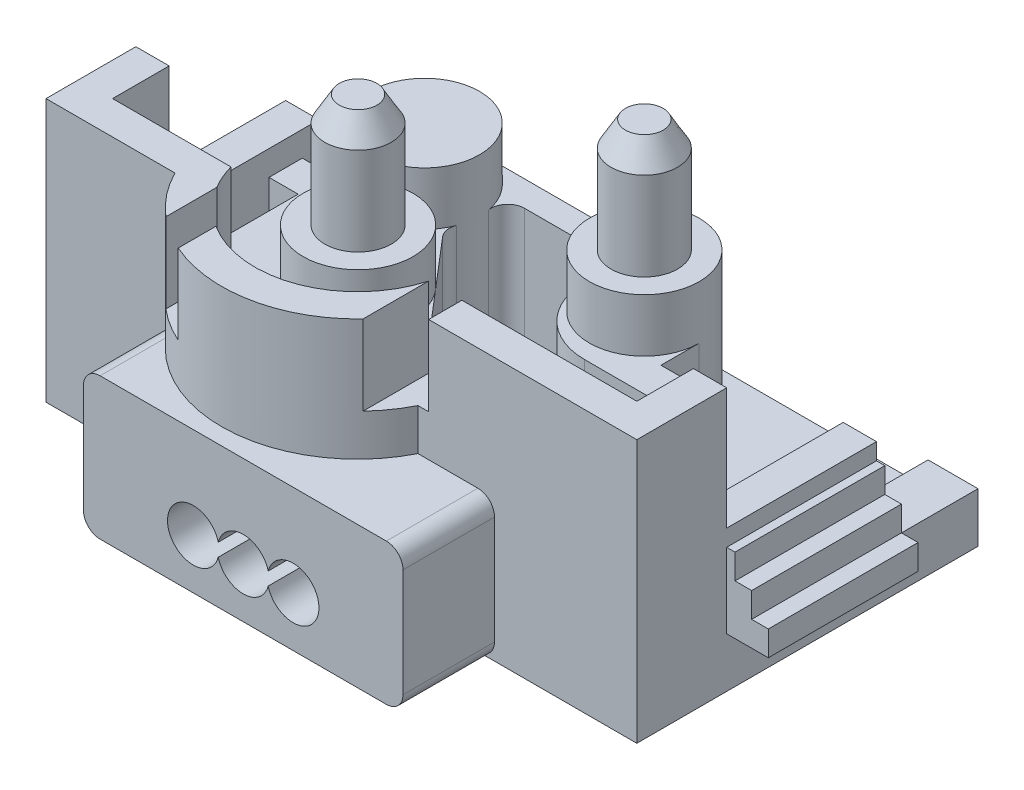
from build123d import *

# Parameters (mm, degrees)
SKETCH1_W             = 35.5
SKETCH1_H             = 20.5
BOSS_EXTRUDE1_DEPTH   = 1.5
BOSS_EXTRUDE2_DEPTH   = 1.5
BOSS_EXTRUDE4_DEPTH   = 9.5
SKETCH6_R             = 3.3
BOSS_EXTRUDE5_DEPTH   = 3.2
SKETCH7_R             = 2
BOSS_EXTRUDE6_DEPTH   = 6.8
BOSS_EXTRUDE6_2_DEPTH = 6.8
CHAMFER1_SIZE         = 1.5
CHAMFER1_SIZE2        = 0.866025404
CHAMFER2_SIZE         = 1.5
CHAMFER2_SIZE2        = 0.866025404
BOSS_EXTRUDE7_DEPTH   = 8
BOSS_EXTRUDE8_DEPTH   = 4.8
BOSS_EXTRUDE9_DEPTH   = 5.5
BOSS_EXTRUDE10_DEPTH  = 9
BOSS_EXTRUDE11_DEPTH  = 9
CUT_EXTRUDE4_DEPTH    = 5.5


with BuildPart() as part:
    # Sketch1 → Boss-Extrude1 (new body)
    with BuildSketch(Plane(origin=(0, 0, 0), x_dir=(1, 0, 0), z_dir=(0, 1, 0))):
        Rectangle(SKETCH1_W, SKETCH1_H)
    extrude(amount=BOSS_EXTRUDE1_DEPTH)

    # Sketch2 → Boss-Extrude2 (add)
    with BuildSketch(Plane(origin=(0, 1.5, 0), x_dir=(1, 0, 0), z_dir=(0, 1, 0))):
        Polygon((17.75, 10.25), (14.75, 10.25), (14.75, -8.25), (-14.75, -8.25), (-14.75, 10.25), (-17.75, 10.25), (-17.75, -10.25), (17.75, -10.25), align=None)
    extrude(amount=BOSS_EXTRUDE2_DEPTH)

    # Sketch4 → Boss-Extrude4 (add)
    with BuildSketch(Plane(origin=(0, 1.5, 0), x_dir=(1, 0, 0), z_dir=(0, 1, 0))):
        with BuildLine():
            ThreePointArc((9.8, 1.45), (8.833452378, 3.783452378), (6.5, 4.75))
            Line((6.5, 4.75), (-6.7, 4.75))
            ThreePointArc((-6.7, 4.75), (-9.033452378, 3.783452378), (-10, 1.45))
            Line((-10, 1.45), (-10, -0.85))
            Line((-10, -0.85), (-11.75, -0.85))
            Line((-11.75, -0.85), (-11.75, -2.85))
            Line((-11.75, -2.85), (-10, -2.85))
            Line((-10, -2.85), (-10, -8.25))
            Line((-10, -8.25), (3, -8.25))
            Line((3, -8.25), (-3.440516213, -0.729311618))
            ThreePointArc((-3.440516213, -0.729311618), (-3.666156861, -0.250346383), (-3.615628786, 0.276690914))
            ThreePointArc((-3.615628786, 0.276690914), (-3.413949819, 1.146892415), (-3.453044202, 2.03930302))
            ThreePointArc((-3.453044202, 2.03930302), (-3.236769385, 2.858747591), (-2.469118203, 3.217879692))
            Line((-2.469118203, 3.217879692), (2.269118203, 3.217879692))
            ThreePointArc((2.269118203, 3.217879692), (3.036769385, 2.858747591), (3.253044202, 2.03930302))
            ThreePointArc((3.253044202, 2.03930302), (3.213287803, 1.745842752), (3.2, 1.45))
            Line((3.2, 1.45), (3.2, 1.15))
            ThreePointArc((3.2, 1.15), (4.371572875, -1.678427125), (7.2, -2.85))
            Line((7.2, -2.85), (9.8, -2.85))
            Line((9.8, -2.85), (11.55, -2.85))
            Line((11.55, -2.85), (11.55, -0.85))
            Line((11.55, -0.85), (9.8, -0.85))
            Line((9.8, -0.85), (9.8, 1.45))
        make_face()
        with BuildLine():
            Line((3, -8.25), (-10, -8.25))
            Line((-10, -8.25), (-10, -10.25))
            ThreePointArc((-10, -10.25), (-2.7, -14.75), (4.6, -10.25))
            Line((4.6, -10.25), (4.6, -8.25))
            Line((4.6, -8.25), (3, -8.25))
        make_face()
    extrude(amount=BOSS_EXTRUDE4_DEPTH)

    # Sketch6 → Boss-Extrude5 (add)
    with BuildSketch(Plane(origin=(0, 11, 0), x_dir=(1, 0, 0), z_dir=(0, 1, 0))):
        with Locations((-6.7, 1.45)):
            Circle(SKETCH6_R)
        with Locations((6.5, 1.45)):
            Circle(SKETCH6_R)
        with Locations((-3.4, -5.85)):
            Circle(SKETCH6_R)
    extrude(amount=BOSS_EXTRUDE5_DEPTH)

    # Sketch8 → Boss-Extrude7 (add)
    with BuildSketch(Plane(origin=(0, 3, 0), x_dir=(1, 0, 0), z_dir=(0, 1, 0))):
        with BuildLine():
            Line((-17.75, -10.25), (-10, -10.25))
            ThreePointArc((-10, -10.25), (-2.7, -14.75), (4.6, -10.25))
            Line((4.6, -10.25), (17.75, -10.25))
            Line((17.75, -10.25), (17.75, -4.85))
            Line((17.75, -4.85), (15.75, -4.85))
            Line((15.75, -4.85), (15.75, -8.25))
            Line((15.75, -8.25), (14.75, -8.25))
            Line((14.75, -8.25), (4.6, -8.25))
            Line((4.6, -8.25), (3.240538696, -8.25))
            ThreePointArc((3.240538696, -8.25), (-2.7, -12.75), (-8.640538696, -8.25))
            Line((-8.640538696, -8.25), (-10, -8.25))
            Line((-10, -8.25), (-14.75, -8.25))
            Line((-14.75, -8.25), (-15.75, -8.25))
            Line((-15.75, -8.25), (-15.75, -4.85))
            Line((-15.75, -4.85), (-17.75, -4.85))
            Line((-17.75, -4.85), (-17.75, -10.25))
        make_face()
    extrude(amount=BOSS_EXTRUDE7_DEPTH)

    # Sketch9 → Boss-Extrude8 (add)
    with BuildSketch(Plane(origin=(0, 11, 0), x_dir=(1, 0, 0), z_dir=(0, 1, 0))):
        Polygon((17.75, -10.25), (17.75, -4.85), (15.75, -4.85), (15.75, -8.25), (5.240538696, -8.25), (5.240538696, -10.25), align=None)
        with BuildLine():
            Line((-17.75, -4.85), (-17.75, -10.25))
            Line((-17.75, -10.25), (-10, -10.25))
            ThreePointArc((-10, -10.25), (-9.127522593, -11.624085625), (-8, -12.797976988))
            Line((-8, -12.797976988), (-8, -9.739998243))
            ThreePointArc((-8, -9.739998243), (-8.369431297, -9.016133462), (-8.640538696, -8.25))
            Line((-8.640538696, -8.25), (-15.75, -8.25))
            Line((-15.75, -8.25), (-15.75, -4.85))
            Line((-15.75, -4.85), (-17.75, -4.85))
        make_face()
        with BuildLine():
            Line((3.240538696, -8.25), (3.240538696, -12.189330653))
            ThreePointArc((3.240538696, -12.189330653), (-1.083725026, -14.588552552), (-6, -14.05398466))
            Line((-6, -14.05398466), (-6, -11.793542506))
            ThreePointArc((-6, -11.793542506), (-0.490410779, -12.340861452), (3.240538696, -8.25))
        make_face()
    extrude(amount=BOSS_EXTRUDE8_DEPTH)

    # Sketch10 → Boss-Extrude9 (add)
    with BuildSketch(Plane.XY.offset(10.25)):
        with BuildLine():
            Line((-10, 1), (-10, 7.5))
            ThreePointArc((-10, 7.5), (-9.707106781, 8.207106781), (-9, 8.5))
            Line((-9, 8.5), (8.2, 8.5))
            ThreePointArc((8.2, 8.5), (8.907106781, 8.207106781), (9.2, 7.5))
            Line((9.2, 7.5), (9.2, 1))
            ThreePointArc((9.2, 1), (8.907106781, 0.292893219), (8.2, 0))
            Line((8.2, 0), (-9, 0))
            ThreePointArc((-9, 0), (-9.707106781, 0.292893219), (-10, 1))
        make_face()
    extrude(amount=BOSS_EXTRUDE9_DEPTH)

    # Sketch11 → Boss-Extrude10 (add)
    with BuildSketch(Plane(origin=(0, 0, 4.85), x_dir=(-1, 0, 0), z_dir=(0, 0, -1))):
        Polygon((-15.75, 8.5), (-17.75, 8.5), (-17.75, 7.5), (-18.25, 7.5), (-18.25, 6), (-19.25, 6), (-19.25, 4.5), (-20.25, 4.5), (-20.25, 3), (-15.75, 3), align=None)
        Polygon((20.25, 4.5), (20.25, 3), (15.75, 3), (15.75, 8.5), (17.75, 8.5), (17.75, 7.5), (18.25, 7.5), (18.25, 6), (19.25, 6), (19.25, 4.5), align=None)
    extrude(amount=BOSS_EXTRUDE10_DEPTH)

    # Sketch12 → Boss-Extrude11 (add)
    with BuildSketch(Plane(origin=(0, 0, 8.25), x_dir=(-1, 0, 0), z_dir=(0, 0, -1))):
        with BuildLine():
            Line((-8.75, 1.5), (-8.75, 6.6))
            ThreePointArc((-8.75, 6.6), (-8.047056275, 8.297056275), (-6.35, 9))
            Line((-6.35, 9), (-6.15, 9))
            ThreePointArc((-6.15, 9), (-4.452943725, 8.297056275), (-3.75, 6.6))
            Line((-3.75, 6.6), (-3.75, 1.5))
            Line((-3.75, 1.5), (-8.75, 1.5))
        make_face()
    extrude(amount=BOSS_EXTRUDE11_DEPTH)

    # Sketch13 → Cut-Extrude4 (cut)
    with BuildSketch(Plane.XY.offset(15.75)):
        with BuildLine():
            ThreePointArc((-1.9, 2.609487516), (-0.4, 1.45), (1.1, 2.609487516))
            ThreePointArc((1.1, 2.609487516), (4.15, 3), (1.1, 3.390512484))
            ThreePointArc((1.1, 3.390512484), (-0.4, 4.55), (-1.9, 3.390512484))
            ThreePointArc((-1.9, 3.390512484), (-4.95, 3), (-1.9, 2.609487516))
        make_face()
    extrude(amount=-CUT_EXTRUDE4_DEPTH, mode=Mode.SUBTRACT)


with BuildPart() as body_2:
    # Sketch7 → Boss-Extrude6 (new body)
    with BuildSketch(Plane(origin=(0, 14.2, 0), x_dir=(1, 0, 0), z_dir=(0, 1, 0))):
        with Locations((-3.4, -5.85)):
            Circle(SKETCH7_R)
    extrude(amount=BOSS_EXTRUDE6_DEPTH)

    # Chamfer1
    chamfer1_edges = [body_2.edges().sort_by_distance(p)[0] for p in [
        (-5.4, 21, 5.85),
    ]]
    chamfer1_side = [body_2.faces().sort_by_distance(p)[0] for p in [
        (-5.4, 17.6, 5.85),
    ]]
    chamfer(chamfer1_edges, length=CHAMFER1_SIZE, length2=CHAMFER1_SIZE2, reference=chamfer1_side[0])


with BuildPart() as body_3:
    # Sketch7 → Boss-Extrude6 2 (new body)
    with BuildSketch(Plane(origin=(0, 14.2, 0), x_dir=(1, 0, 0), z_dir=(0, 1, 0))):
        with Locations((6.5, 1.45)):
            Circle(SKETCH7_R)
    extrude(amount=BOSS_EXTRUDE6_2_DEPTH)

    # Chamfer2
    chamfer2_edges = [body_3.edges().sort_by_distance(p)[0] for p in [
        (4.5, 21, -1.45),
    ]]
    chamfer2_side = [body_3.faces().sort_by_distance(p)[0] for p in [
        (4.5, 17.6, -1.45),
    ]]
    chamfer(chamfer2_edges, length=CHAMFER2_SIZE, length2=CHAMFER2_SIZE2, reference=chamfer2_side[0])


solid = Compound([part.part, body_2.part, body_3.part])
